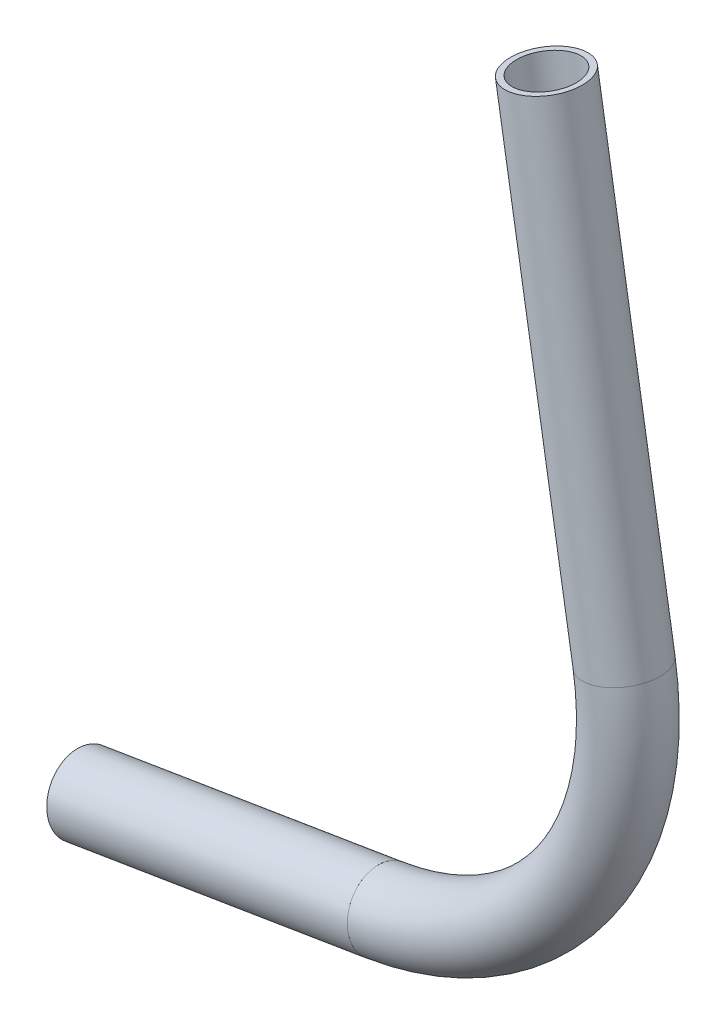
from build123d import *

# Parameters (mm, degrees)
SKETCH11_R                = 6.35
SKETCH11_R_2              = 5.2832
PIPE_0_5_SCH_40_1_DEPTH   = 53.19414965
SKETCH11_ON_SEGMENT_2_R   = 6.35
SKETCH11_ON_SEGMENT_2_R_2 = 5.2832
PIPE_0_5_SCH_40_1_2_ANGLE = 90
SKETCH11_ON_SEGMENT_3_R   = 6.35
SKETCH11_ON_SEGMENT_3_R_2 = 5.2832
PIPE_0_5_SCH_40_1_3_DEPTH = 83.782915117


with BuildPart() as part:
    # Sketch11 → Pipe 0.5 SCH 40(1) (new body)
    with BuildSketch(Plane(origin=(99.62622679, 633.200738698, 0), x_dir=(-0.1618236311412458, 0.9868196959953028, 0), z_dir=(0.986819695995303, 0.16182363114124582, 0))):
        Circle(SKETCH11_R)
        Circle(SKETCH11_R_2, mode=Mode.SUBTRACT)
    extrude(amount=PIPE_0_5_SCH_40_1_DEPTH)


with BuildPart() as body_2:
    # Sketch11 on segment 2 (carried to the start of arc 2) → Pipe 0.5 SCH 40_1 2 (revolve)
    with BuildSketch(Plane(origin=(152.119261376, 641.80880915, 0), x_dir=(-0.161823631, 0.986819696, 0), z_dir=(0.986819696, 0.161823631, 0))):
        Circle(SKETCH11_ON_SEGMENT_2_R)
        Circle(SKETCH11_ON_SEGMENT_2_R_2, mode=Mode.SUBTRACT)
    revolve(axis=Axis((143.898620914, 691.939249707, 0), (0, 0, 1)), revolution_arc=PIPE_0_5_SCH_40_1_2_ANGLE)


with BuildPart() as body_3:
    # Sketch11 on segment 3 (carried to segment 3) → Pipe 0.5 SCH 40_1 3 (new body)
    with BuildSketch(Plane(origin=(194.02906147, 700.159890169, 0), x_dir=(-0.986819696, -0.161823631, 0), z_dir=(-0.161823631, 0.986819696, 0))):
        Circle(SKETCH11_ON_SEGMENT_3_R)
        Circle(SKETCH11_ON_SEGMENT_3_R_2, mode=Mode.SUBTRACT)
    extrude(amount=PIPE_0_5_SCH_40_1_3_DEPTH)


solid = Compound([part.part, body_2.part, body_3.part])
